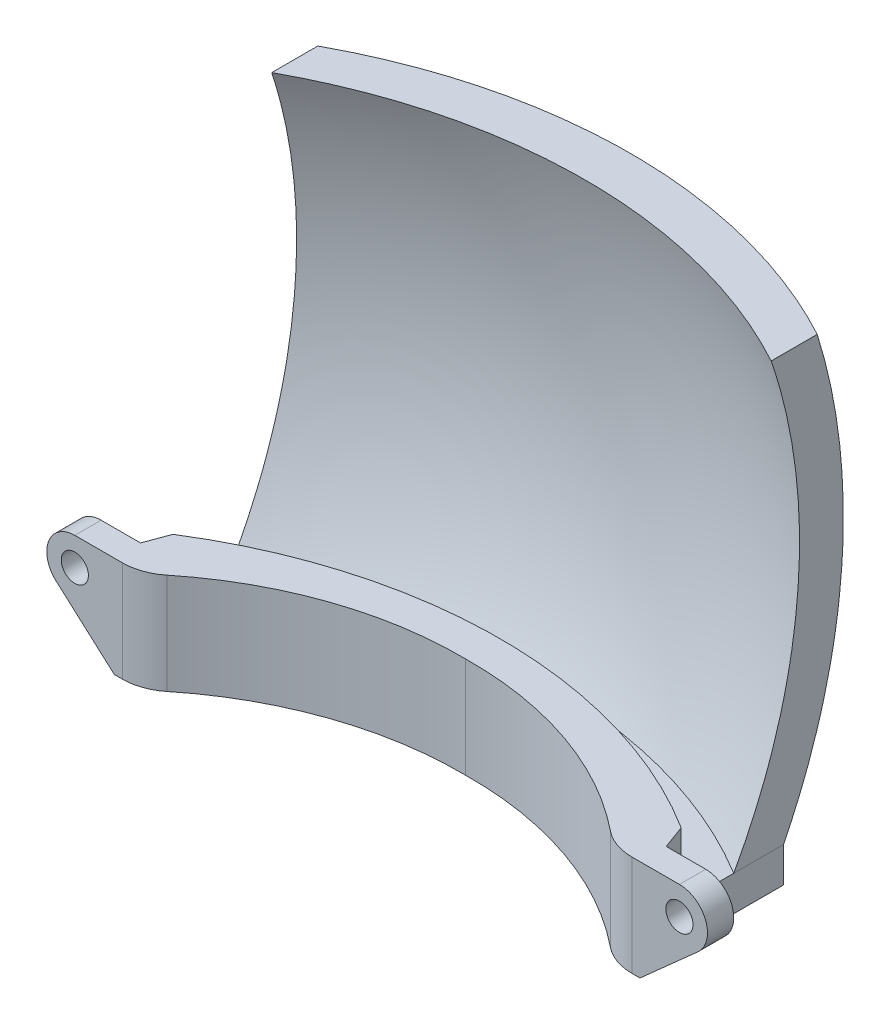
from build123d import *

# Parameters (mm, degrees)
REVOLVE4_ANGLE      = 100
SKETCH4_W           = 58
SKETCH4_H           = 44.980583024
CUT_EXTRUDE3_DEPTH  = 78.595827384
BOSS_EXTRUDE1_DEPTH = 4
BOSS_EXTRUDE2_DEPTH = 7.5
CUT_EXTRUDE4_REACH  = 58.775
SKETCH7_R           = 1.55
CUT_EXTRUDE5_REACH  = 58.775


with BuildPart() as part:
    # Sketch15 → Revolve4 (revolve, symmetric)
    with BuildSketch(Plane(origin=(0, 5, 0), x_dir=(1, 0, 0), z_dir=(0, 1, 0))) as revolve4_sk:
        with BuildLine():
            Line((-29, 25.299635035), (-29, 30.299635035))
            ThreePointArc((-29, 30.299635035), (0, 37.5), (29, 30.299635035))
            Line((29, 30.299635035), (29, 25.299635035))
            ThreePointArc((29, 25.299635035), (0, 32.5), (-29, 25.299635035))
        make_face()
    revolve(axis=Axis((-1000, 5, 33.5), (1, 0, 0)), revolution_arc=REVOLVE4_ANGLE / 2)
    revolve(revolve4_sk.sketch, axis=Axis((-1000, 5, 33.5), (-1, 0, 0)), revolution_arc=REVOLVE4_ANGLE / 2)

    # Sketch4 → Cut-Extrude3 (cut, through all)
    with BuildSketch(Plane.XY.offset(-44.953279354)):
        Polygon((-29, 24), (-29, -24), (-28.5, 24), (28.5, 24), (29, -24), (29, 24), (29, 68.980583024), (-29, 68.980583024), align=None)
        with Locations((0, -46.490291512)):
            Rectangle(SKETCH4_W, SKETCH4_H)
    extrude(amount=CUT_EXTRUDE3_DEPTH, mode=Mode.SUBTRACT)

    # Sketch5 → Boss-Extrude1 (add)
    with BuildSketch(Plane.XZ.offset(24)):
        with BuildLine():
            Line((-29, -17.65072903), (-29, -23.327752293))
            add(Edge.make_bspline(
                [(-29, -23.327752293), (-26.821431513, -24.622094951), (-24.570094076, -25.764660778), (-21.084353939, -27.251719124), (-19.904261596, -27.709488716), (-17.50708235, -28.547867009), (-16.288451369, -28.928902372), (-12.585115962, -29.949982234), (-10.092475922, -30.458162245), (-6.318753033, -30.967883479), (-5.055031842, -31.095555565), (-2.515871872, -31.265772539), (-1.238142477, -31.308316997), (2.599039789, -31.305542579), (5.127664186, -31.131070792), (10.128325346, -30.450966671), (12.600354037, -29.945287089), (16.265459061, -28.935487097), (17.479981566, -28.556873367), (19.894295767, -27.713438676), (21.081949842, -27.252793603), (24.580473818, -25.760134814), (26.830562028, -24.616670281), (29, -23.327752293)],
                knots=[0, 0, 0, 0, 0.125, 0.125, 0.1875, 0.1875, 0.25, 0.25, 0.375, 0.375, 0.4375, 0.4375, 0.5, 0.5, 0.625, 0.625, 0.75, 0.75, 0.8125, 0.8125, 0.875, 0.875, 1, 1, 1, 1], degree=3))
            Line((29, -23.327752293), (29, -17.65072903))
            Line((29, -17.65072903), (29, -11.65072903))
            Line((29, -11.65072903), (30, -8.95072903))
            Line((30, -8.95072903), (38, -8.95072903))
            Line((38, -8.95072903), (38, -5.95072903))
            Line((38, -5.95072903), (29.069393239, -5.95072903))
            ThreePointArc((29.069393239, -5.95072903), (27.071722238, -6.293051894), (25.302000724, -7.280958839))
            ThreePointArc((25.302000724, -7.280958839), (13.415329399, -13.867171478), (0, -16.035140397))
            ThreePointArc((0, -16.035140397), (-13.415329399, -13.867171478), (-25.302000724, -7.280958839))
            ThreePointArc((-25.302000724, -7.280958839), (-27.071722238, -6.293051894), (-29.069393239, -5.95072903))
            Line((-29.069393239, -5.95072903), (-38, -5.95072903))
            Line((-38, -5.95072903), (-38, -8.95072903))
            Line((-38, -8.95072903), (-30, -8.95072903))
            Line((-30, -8.95072903), (-29, -11.65072903))
            Line((-29, -11.65072903), (-29, -17.65072903))
        make_face()
    extrude(amount=BOSS_EXTRUDE1_DEPTH)

    # Sketch6 → Boss-Extrude2 (add)
    with BuildSketch(Plane(origin=(0, -24, 0), x_dir=(1, 0, 0), z_dir=(0, 1, 0))):
        with BuildLine():
            ThreePointArc((-29, 11.65072903), (0, 20.006932047), (29, 11.65072903))
            Line((29, 11.65072903), (30, 8.95072903))
            Line((30, 8.95072903), (38, 8.95072903))
            Line((38, 8.95072903), (38, 5.95072903))
            Line((38, 5.95072903), (29.069393239, 5.95072903))
            ThreePointArc((29.069393239, 5.95072903), (27.071722238, 6.293051894), (25.302000724, 7.280958839))
            ThreePointArc((25.302000724, 7.280958839), (13.415329399, 13.867171478), (0, 16.035140397))
            ThreePointArc((0, 16.035140397), (-13.415329399, 13.867171478), (-25.302000724, 7.280958839))
            ThreePointArc((-25.302000724, 7.280958839), (-27.071722238, 6.293051894), (-29.069393239, 5.95072903))
            Line((-29.069393239, 5.95072903), (-38, 5.95072903))
            Line((-38, 5.95072903), (-38, 8.95072903))
            Line((-38, 8.95072903), (-30, 8.95072903))
            Line((-30, 8.95072903), (-29, 11.65072903))
        make_face()
    extrude(amount=BOSS_EXTRUDE2_DEPTH)

    # Sketch7 → Cut-Extrude4 (cut, up to next)
    with BuildSketch(Plane.XY.offset(-5.95072903), mode=Mode.PRIVATE) as cut_extrude4_sk1:
        with Locations((-34.5, -19.7)):
            Circle(SKETCH7_R)
    cut_extrude4_tool1 = extrude(cut_extrude4_sk1.sketch, amount=-CUT_EXTRUDE4_REACH, mode=Mode.PRIVATE) & part.part
    # Sketch7 → Cut-Extrude4 (cut, up to next)
    with BuildSketch(Plane.XY.offset(-5.95072903), mode=Mode.PRIVATE) as cut_extrude4_sk2:
        with Locations((34.5, -19.7)):
            Circle(SKETCH7_R)
    cut_extrude4_tool2 = extrude(cut_extrude4_sk2.sketch, amount=-CUT_EXTRUDE4_REACH, mode=Mode.PRIVATE) & part.part
    add(cut_extrude4_tool1.solids().sort_by_distance((-34.5, -19.7, -5.950729))[0], mode=Mode.SUBTRACT)
    add(cut_extrude4_tool2.solids().sort_by_distance((34.5, -19.7, -5.950729))[0], mode=Mode.SUBTRACT)

    # Sketch8 → Cut-Extrude5 (cut, up to next)
    with BuildSketch(Plane.XY.offset(-5.95072903), mode=Mode.PRIVATE) as cut_extrude5_sk1:
        with BuildLine():
            Line((-30, -28), (-36.629694691, -22.088388688))
            ThreePointArc((-36.629694691, -22.088388688), (-37.490221045, -18.56044829), (-34.5, -16.5))
            Line((-34.5, -16.5), (-38, -16.5))
            Line((-38, -16.5), (-38, -28))
            Line((-38, -28), (-30, -28))
        make_face()
    cut_extrude5_tool1 = extrude(cut_extrude5_sk1.sketch, amount=-CUT_EXTRUDE5_REACH, mode=Mode.PRIVATE) & part.part
    # Sketch8 → Cut-Extrude5 (cut, up to next)
    with BuildSketch(Plane.XY.offset(-5.95072903), mode=Mode.PRIVATE) as cut_extrude5_sk2:
        with BuildLine():
            Line((38, -16.5), (38, -28))
            Line((38, -28), (30, -28))
            Line((30, -28), (36.629694691, -22.088388688))
            ThreePointArc((36.629694691, -22.088388688), (37.490221045, -18.56044829), (34.5, -16.5))
            Line((34.5, -16.5), (38, -16.5))
        make_face()
    cut_extrude5_tool2 = extrude(cut_extrude5_sk2.sketch, amount=-CUT_EXTRUDE5_REACH, mode=Mode.PRIVATE) & part.part
    add(cut_extrude5_tool1.solids().sort_by_distance((-35.568693, -24.725507, -5.950729))[0], mode=Mode.SUBTRACT)
    add(cut_extrude5_tool2.solids().sort_by_distance((35.568693, -24.725507, -5.950729))[0], mode=Mode.SUBTRACT)


solid = part.part
